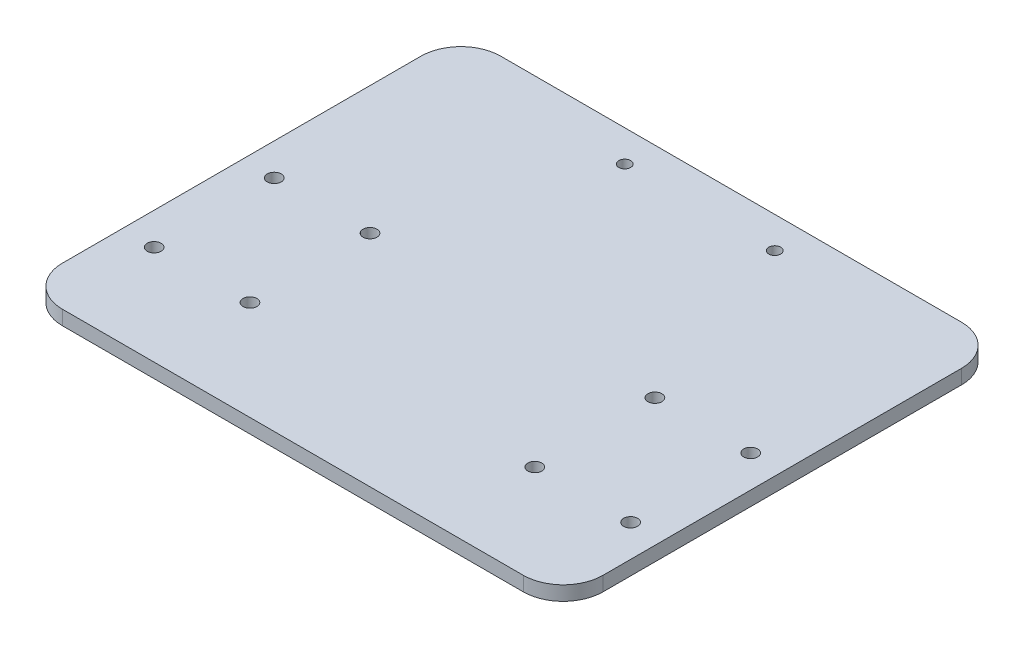
from build123d import *

# Parameters (mm, degrees)
SKETCH_6_W      = 135.527465206
SKETCH_6_H      = 109.875291841
SKETCH_6_R      = 1.75
SKETCH_6_R_2    = 1.5
EXTRUDE_2_DEPTH = 3.6
FILLET_1_R      = 10
FILLET_2_R      = 10
FILLET_3_R      = 10
FILLET_4_R      = 10


with BuildPart() as part:
    # 草图6 → 凸台-拉伸2 (new body)
    with BuildSketch(Plane(origin=(0, 0, 0), x_dir=(1, 0, 0), z_dir=(0, 1, 0))):
        with Locations((95, 84.937645921)):
            Rectangle(SKETCH_6_W, SKETCH_6_H)
        with Locations((35.286267397, 54.95)):
            Circle(SKETCH_6_R, mode=Mode.SUBTRACT)
        with Locations((59.286267397, 54.95)):
            Circle(SKETCH_6_R, mode=Mode.SUBTRACT)
        with Locations((35.286267397, 85.05)):
            Circle(SKETCH_6_R, mode=Mode.SUBTRACT)
        with Locations((59.286267397, 85.05)):
            Circle(SKETCH_6_R, mode=Mode.SUBTRACT)
        with Locations((76.2, 132)):
            Circle(SKETCH_6_R_2, mode=Mode.SUBTRACT)
        with Locations((113.8, 132)):
            Circle(SKETCH_6_R_2, mode=Mode.SUBTRACT)
        with Locations((130.713732603, 85.05)):
            Circle(SKETCH_6_R, mode=Mode.SUBTRACT)
        with Locations((154.713732603, 54.95)):
            Circle(SKETCH_6_R, mode=Mode.SUBTRACT)
        with Locations((154.713732603, 85.05)):
            Circle(SKETCH_6_R, mode=Mode.SUBTRACT)
        with Locations((130.713732603, 54.95)):
            Circle(SKETCH_6_R, mode=Mode.SUBTRACT)
    extrude(amount=EXTRUDE_2_DEPTH)

    # 圆角1
    fillet_1_edges = [part.edges().sort_by_distance(p)[0] for p in [
        (27.236267397, 1.8, -30),
    ]]
    fillet(fillet_1_edges, radius=FILLET_1_R)

    # 圆角2
    fillet_2_edges = [part.edges().sort_by_distance(p)[0] for p in [
        (27.236267397, 1.8, -139.875291841),
    ]]
    fillet(fillet_2_edges, radius=FILLET_2_R)

    # 圆角3
    fillet_3_edges = [part.edges().sort_by_distance(p)[0] for p in [
        (162.763732603, 1.8, -139.875291841),
    ]]
    fillet(fillet_3_edges, radius=FILLET_3_R)

    # 圆角4
    fillet_4_edges = [part.edges().sort_by_distance(p)[0] for p in [
        (162.763732603, 1.8, -30),
    ]]
    fillet(fillet_4_edges, radius=FILLET_4_R)


solid = part.part
